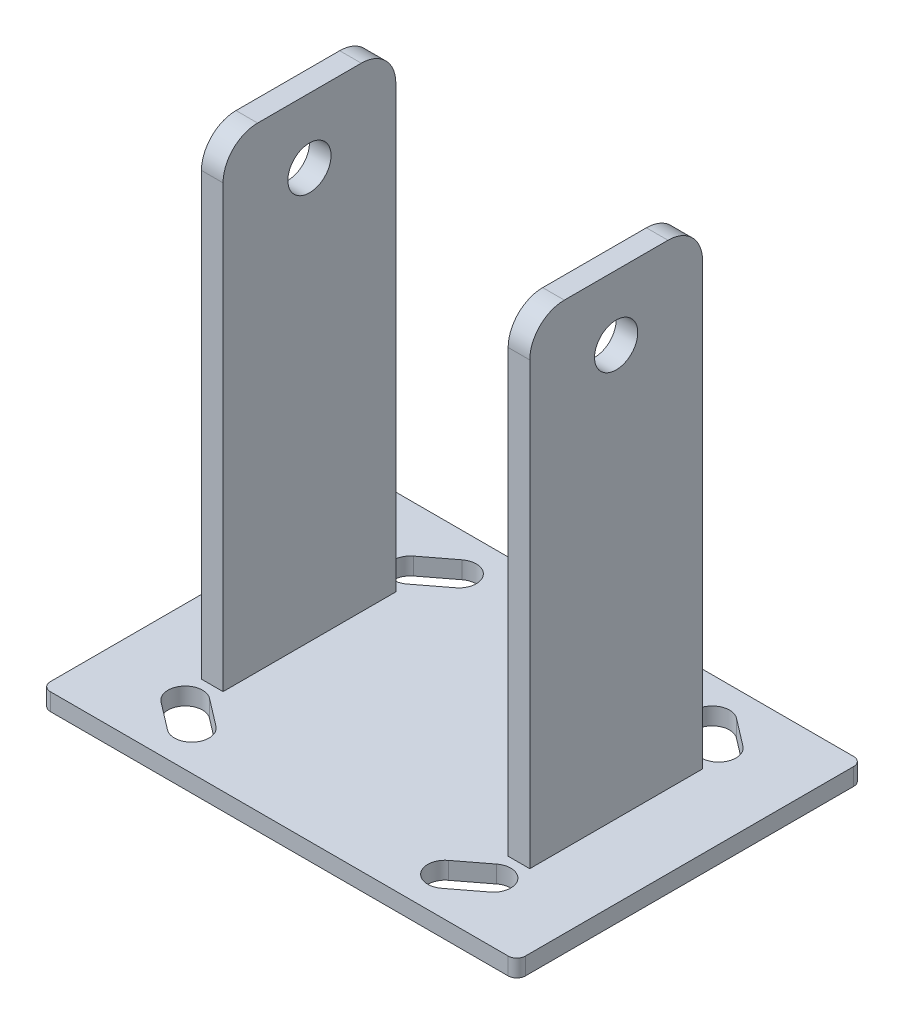
from build123d import *

# Parameters (mm, degrees)
SKETCH1_W           = 139.7
SKETCH1_H           = 101.6
BOSS_EXTRUDE1_DEPTH = 5.08
FILLET1_R           = 2.54
SKETCH2_W           = 6.35
SKETCH2_H           = 50.8
BOSS_EXTRUDE2_DEPTH = 139.7
FILLET2_R           = 10.16
SKETCH3_R           = 6.35
CUT_EXTRUDE1_DEPTH  = 119.11


with BuildPart() as part:
    # Sketch1 → Boss-Extrude1 (new body)
    with BuildSketch(Plane(origin=(0, 0, 0), x_dir=(1, 0, 0), z_dir=(0, 1, 0))):
        Rectangle(SKETCH1_W, SKETCH1_H)
        with BuildLine():
            ThreePointArc((-40.325508755, -43.316184338), (-33.204324417, -42.366693093), (-34.153815662, -35.245508755))
            Line((-34.153815662, -35.245508755), (-42.224491245, -29.073815662))
            ThreePointArc((-42.224491245, -29.073815662), (-49.345675583, -30.023306907), (-48.396184338, -37.144491245))
            Line((-48.396184338, -37.144491245), (-40.325508755, -43.316184338))
        make_face(mode=Mode.SUBTRACT)
        with BuildLine():
            ThreePointArc((-48.396184338, 37.144491245), (-49.345675583, 30.023306907), (-42.224491245, 29.073815662))
            Line((-42.224491245, 29.073815662), (-34.153815662, 35.245508755))
            ThreePointArc((-34.153815662, 35.245508755), (-33.204324417, 42.366693093), (-40.325508755, 43.316184338))
            Line((-40.325508755, 43.316184338), (-48.396184338, 37.144491245))
        make_face(mode=Mode.SUBTRACT)
        with BuildLine():
            ThreePointArc((40.325508755, 43.316184338), (33.204324417, 42.366693093), (34.153815662, 35.245508755))
            Line((34.153815662, 35.245508755), (42.224491245, 29.073815662))
            ThreePointArc((42.224491245, 29.073815662), (49.345675583, 30.023306907), (48.396184338, 37.144491245))
            Line((48.396184338, 37.144491245), (40.325508755, 43.316184338))
        make_face(mode=Mode.SUBTRACT)
        with BuildLine():
            Line((48.396184338, -37.144491245), (40.325508755, -43.316184338))
            ThreePointArc((40.325508755, -43.316184338), (33.204324417, -42.366693093), (34.153815662, -35.245508755))
            Line((34.153815662, -35.245508755), (42.224491245, -29.073815662))
            ThreePointArc((42.224491245, -29.073815662), (49.345675583, -30.023306907), (48.396184338, -37.144491245))
        make_face(mode=Mode.SUBTRACT)
    extrude(amount=BOSS_EXTRUDE1_DEPTH)

    # Fillet1
    fillet1_edges = [part.edges().sort_by_distance(p)[0] for p in [
        (69.85, 2.54, -50.8),
        (69.85, 2.54, 50.8),
        (-69.85, 2.54, 50.8),
        (-69.85, 2.54, -50.8),
    ]]
    fillet(fillet1_edges, radius=FILLET1_R)

    # Sketch2 → Boss-Extrude2 (add)
    with BuildSketch(Plane(origin=(0, 5.08, 0), x_dir=(1, 0, 0), z_dir=(0, 1, 0))):
        with Locations((45.085, 0)):
            Rectangle(SKETCH2_W, SKETCH2_H)
        with Locations((-45.085, 0)):
            Rectangle(SKETCH2_W, SKETCH2_H)
    extrude(amount=BOSS_EXTRUDE2_DEPTH)

    # Fillet2
    fillet2_edges = [part.edges().sort_by_distance(p)[0] for p in [
        (-45.085, 144.78, -25.4),
        (-45.085, 144.78, 25.4),
        (45.085, 144.78, -25.4),
        (45.085, 144.78, 25.4),
    ]]
    fillet(fillet2_edges, radius=FILLET2_R)

    # Sketch3 → Cut-Extrude1 (cut, through all)
    with BuildSketch(Plane.ZY.offset(48.26)):
        with Locations((0, 125.73)):
            Circle(SKETCH3_R)
    extrude(amount=-CUT_EXTRUDE1_DEPTH, mode=Mode.SUBTRACT)


solid = part.part
